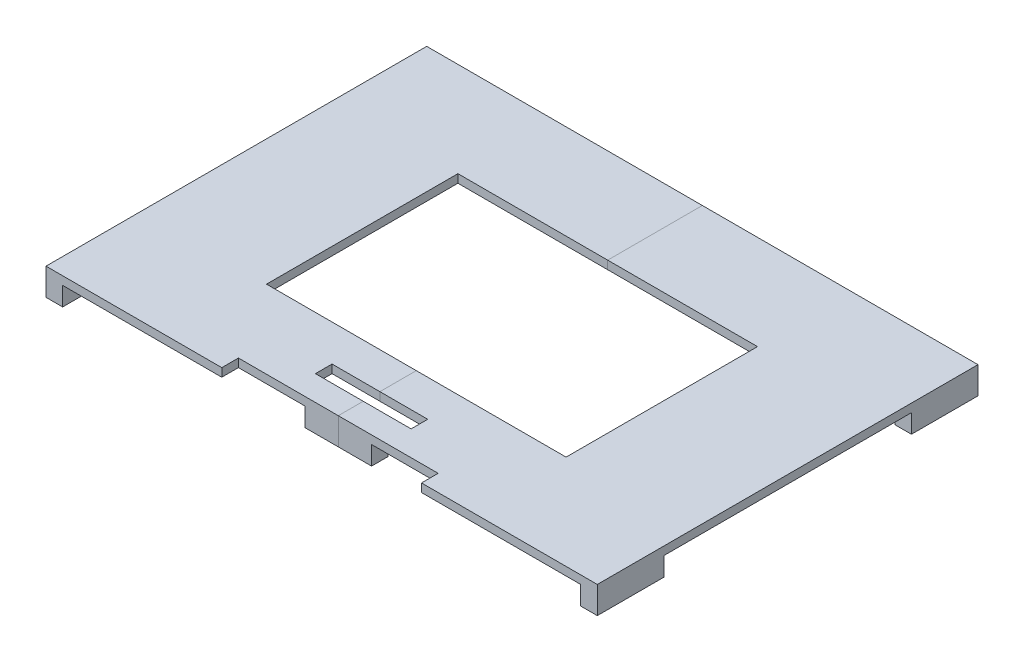
from build123d import *

# Parameters (mm, degrees)
SKETCH1_W           = 420.6875
SKETCH1_H           = 290.5125
BOSS_EXTRUDE1_DEPTH = 6.35
SKETCH2_W           = 228.6
SKETCH2_H           = 146.05
SKETCH2_W_2         = 73.025
SKETCH2_H_2         = 12.7
SKETCH2_W_3         = 152.4
CUT_EXTRUDE1_DEPTH  = 7.35
SKETCH4_W           = 12.7
SKETCH4_H           = 50.8
SKETCH4_W_2         = 50.8
SKETCH4_H_2         = 12.7
BOSS_EXTRUDE2_DEPTH = 14.2875


with BuildPart() as part:
    # Sketch1 → Boss-Extrude1 (new body)
    with BuildSketch(Plane(origin=(0, 0, 0), x_dir=(1, 0, 0), z_dir=(0, 1, 0))):
        Rectangle(SKETCH1_W, SKETCH1_H)
    extrude(amount=BOSS_EXTRUDE1_DEPTH)

    # Sketch2 → Cut-Extrude1 (cut, through all)
    with BuildSketch(Plane(origin=(0, 6.35, 0), x_dir=(1, 0, 0), z_dir=(0, 1, 0))):
        Rectangle(SKETCH2_W, SKETCH2_H)
        with Locations((0, -107.15625)):
            Rectangle(SKETCH2_W_2, SKETCH2_H_2)
        with Locations((0, -138.90625)):
            Rectangle(SKETCH2_W_3, SKETCH2_H_2)
    extrude(amount=-CUT_EXTRUDE1_DEPTH, mode=Mode.SUBTRACT)

    # Sketch4 → Boss-Extrude2 (add)
    with BuildSketch(Plane.XZ):
        with Locations((-203.99375, 119.85625)):
            Rectangle(SKETCH4_W, SKETCH4_H)
        with Locations((203.99375, 119.85625)):
            Rectangle(SKETCH4_W, SKETCH4_H)
        with Locations((-203.99375, -119.85625)):
            Rectangle(SKETCH4_W, SKETCH4_H)
        with Locations((203.99375, -119.85625)):
            Rectangle(SKETCH4_W, SKETCH4_H)
        with Locations((0, 126.20625)):
            Rectangle(SKETCH4_W_2, SKETCH4_H_2)
        with Locations((0, -138.90625)):
            Rectangle(SKETCH4_W_2, SKETCH4_H_2)
    extrude(amount=BOSS_EXTRUDE2_DEPTH)


with BuildPart() as body_2:
    # Split1: the piece on the far side of the plane
    add(part.part)
    split(bisect_by=Plane(origin=(0, 0, 0), x_dir=(0, 0, 1), z_dir=(1, 0, 0)), keep=Keep.BOTTOM)


with BuildPart() as part_1:
    add(part.part)

    # Split1
    split(bisect_by=Plane(origin=(0, 0, 0), x_dir=(0, 0, 1), z_dir=(1, 0, 0)), keep=Keep.TOP)


solid = Compound([body_2.part, part_1.part])
